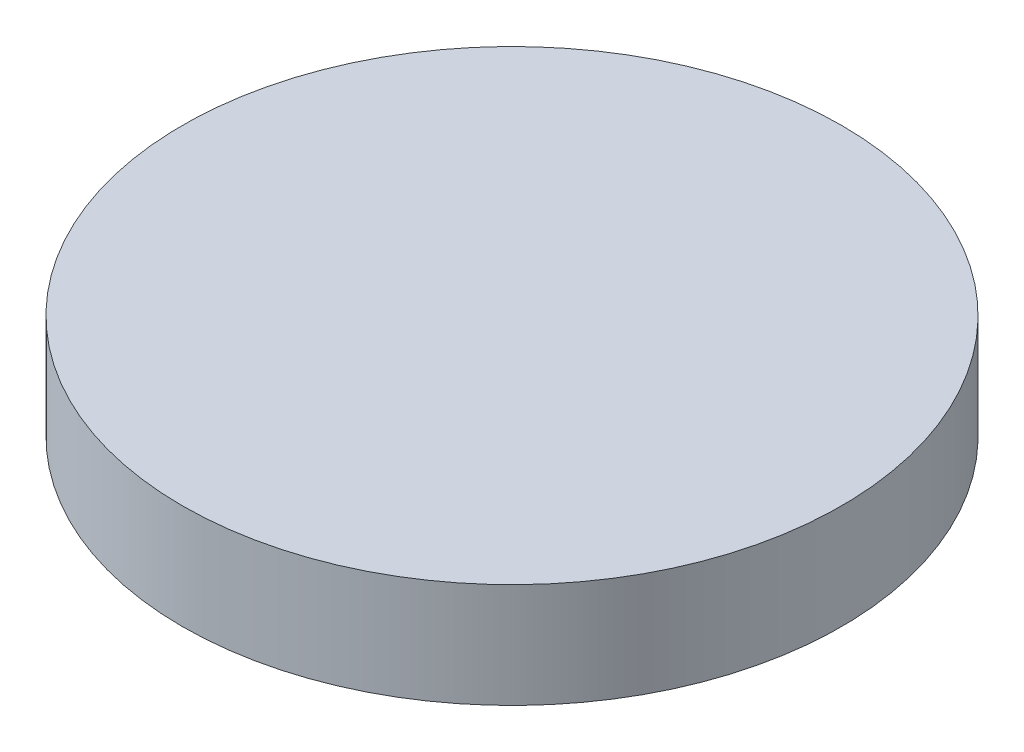
from build123d import *

# Parameters (mm, degrees)
SKETCH1_R           = 20
BOSS_EXTRUDE1_DEPTH = 6.35


with BuildPart() as part:
    # Sketch1 → Boss-Extrude1 (new body)
    with BuildSketch(Plane(origin=(0, 0, 0), x_dir=(1, 0, 0), z_dir=(0, 1, 0))):
        Circle(SKETCH1_R)
    extrude(amount=BOSS_EXTRUDE1_DEPTH)


solid = part.part
